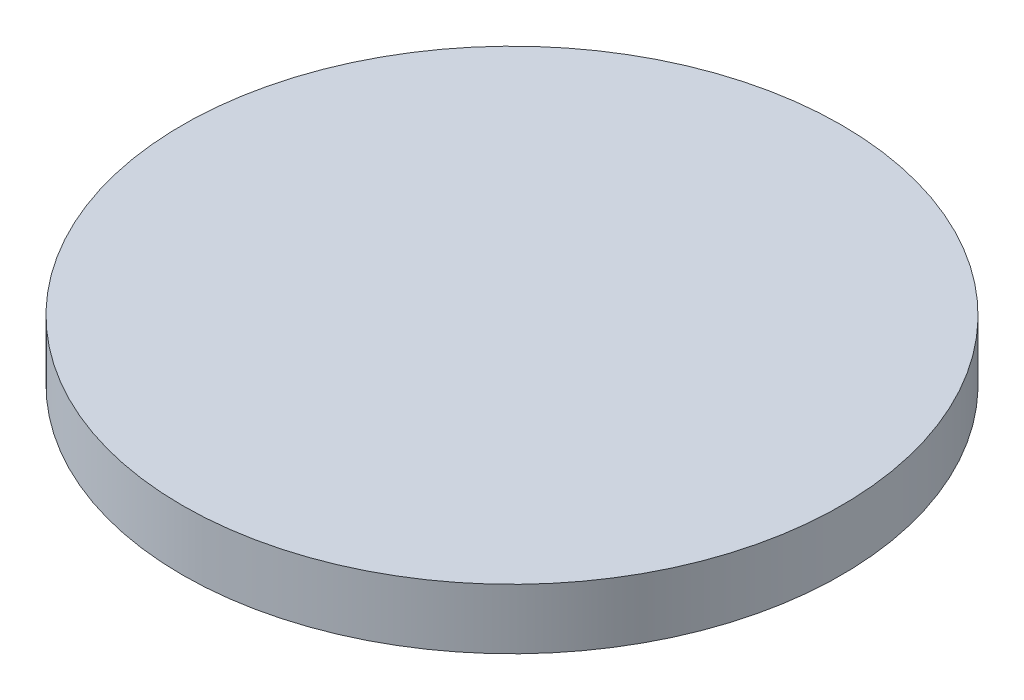
from build123d import *

# Parameters (mm, degrees)
SKETCH1_R           = 11.5
BOSS_EXTRUDE1_DEPTH = 2.1


with BuildPart() as part:
    # Sketch1 → Boss-Extrude1 (new body)
    with BuildSketch(Plane(origin=(0, 0, 0), x_dir=(1, 0, 0), z_dir=(0, 1, 0))):
        Circle(SKETCH1_R)
    extrude(amount=BOSS_EXTRUDE1_DEPTH)


solid = part.part
